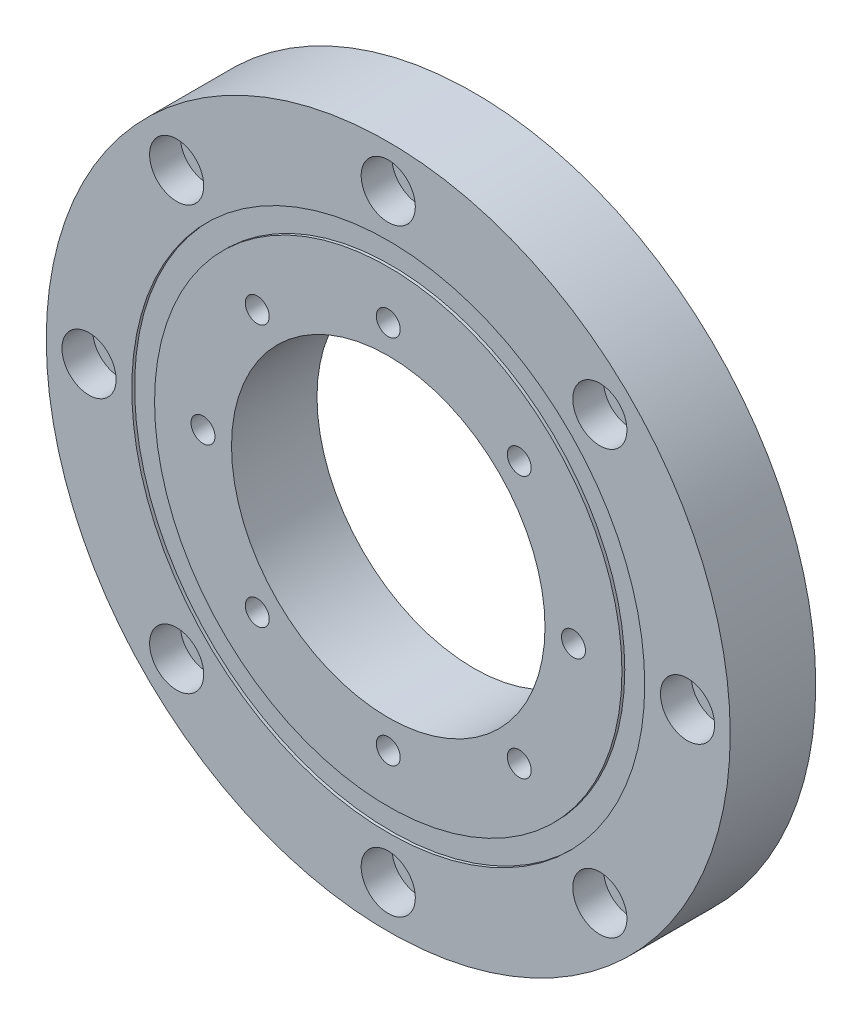
from build123d import *

# Parameters (mm, degrees)
SKETCH_1_R                   = 60
EXTRUDE_1_DEPTH              = 7.5
SKETCH_2_R                   = 27.5
CUT_EXTRUDE_1_DEPTH          = 16
SKETCH_3_R                   = 45
SKETCH_3_R_2                 = 41
CUT_EXTRUDE_2_DEPTH          = 0.5
HOLE_WIZARD_M5_1_D           = 5.5
HOLE_WIZARD_M5_1_CBORE_D     = 9.5
HOLE_WIZARD_M5_1_CBORE_DEPTH = 5.4
M5X0_8_1_D                   = 4.2
PATTERN_CIRCULAR_1_COUNT     = 8


with BuildPart() as part:
    # 草圖1 → 填料-伸長1 (new body, symmetric)
    with BuildSketch(Plane.XY):
        Circle(SKETCH_1_R)
    extrude(amount=EXTRUDE_1_DEPTH, both=True)

    # 草圖2 → 除料-伸長1 (cut, through all)
    with BuildSketch(Plane.XY.offset(7.5)):
        Circle(SKETCH_2_R)
    extrude(amount=-CUT_EXTRUDE_1_DEPTH, mode=Mode.SUBTRACT)

    # 草圖3 → 除料-伸長2 (cut)
    with BuildSketch(Plane.XY.offset(7.5)):
        Circle(SKETCH_3_R)
        Circle(SKETCH_3_R_2, mode=Mode.SUBTRACT)
    cut_extrude_2 = extrude(amount=-CUT_EXTRUDE_2_DEPTH, mode=Mode.SUBTRACT)

    # 鏡射1: 除料-伸長2 across plane
    add(cut_extrude_2.mirror(Plane.XY), mode=Mode.SUBTRACT)

    # M5 凹頭蓋螺釘的柱孔1 (through all)
    with Locations(Plane.XY.offset(7.5)):
        with Locations((0, 52.5)):
            hole_wizard_m5_1 = CounterBoreHole(HOLE_WIZARD_M5_1_D / 2, HOLE_WIZARD_M5_1_CBORE_D / 2, HOLE_WIZARD_M5_1_CBORE_DEPTH)

    # M5x0.8 螺紋孔1 (through all)
    with Locations(Plane.XY.offset(7.5)):
        with Locations((0, 32.5)):
            m5x0_8_1 = Hole(M5X0_8_1_D / 2)

    # 環狀複製排列1: M5 凹頭蓋螺釘的柱孔1, M5x0.8 螺紋孔1 ×8 about axis
    pattern_circular_1_axis = Axis((0, 0, 0), (0, 0, 1))
    for i in range(1, PATTERN_CIRCULAR_1_COUNT):
        add(hole_wizard_m5_1.rotate(pattern_circular_1_axis, i * 360 / PATTERN_CIRCULAR_1_COUNT), mode=Mode.SUBTRACT)
        add(m5x0_8_1.rotate(pattern_circular_1_axis, i * 360 / PATTERN_CIRCULAR_1_COUNT), mode=Mode.SUBTRACT)


solid = part.part
